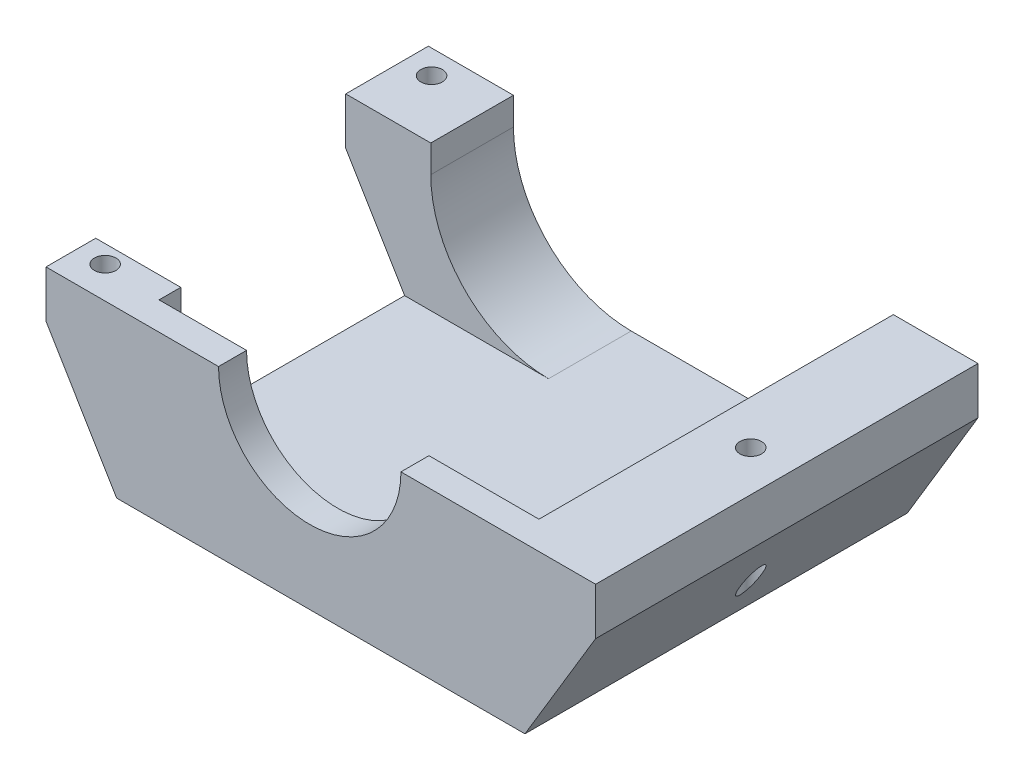
from build123d import *

# Parameters (mm, degrees)
SKETCH1_W                           = 139.991389113
SKETCH1_H                           = 97.393342316
PICOVER_DEPTH                       = 40
PICOVER_DEPTH_BACK                  = 2
SKETCH2_W                           = 96.759944342
SKETCH2_H                           = 90.25941534
OPENINGFORPI_DEPTH                  = 37
SKETCH3_R                           = 23.23056694
HOLETOACCESSSDCARD_DEPTH            = 7.133927
SKETCH4_W                           = 18
SKETCH4_H                           = 97.393342316
CUTAWAYSTHATDEFINESCREWPLATES_DEPTH = 30
BOSS_EXTRUDE1_DEPTH                 = 97.393342
SKETCH6_W                           = 63.672875613
SKETCH6_H                           = 37
HOLEFORPOWERHDMIAUDIO_DEPTH         = 30
SKETCH5_R                           = 2.75
CUT_EXTRUDE5_DEPTH                  = 43
SKETCH7_R                           = 2.75
CUT_EXTRUDE7_DEPTH                  = 30
FILLET1_R                           = 30
FILLET2_R                           = 30


with BuildPart() as part:
    # Sketch1 → PiCover (new body, two sides)
    with BuildSketch(Plane(origin=(0, 0, 0), x_dir=(1, 0, 0), z_dir=(0, 1, 0))) as picover_sk:
        with Locations((69.995694556, 48.696671158)):
            Rectangle(SKETCH1_W, SKETCH1_H)
    extrude(amount=PICOVER_DEPTH)
    extrude(picover_sk.sketch, amount=-PICOVER_DEPTH_BACK)

    # Sketch2 → OpeningForPi (cut)
    with BuildSketch(Plane(origin=(0, 40, 0), x_dir=(1, 0, 0), z_dir=(0, 1, 0))):
        with Locations((70.044375284, 52.263634646)):
            Rectangle(SKETCH2_W, SKETCH2_H)
    extrude(amount=-OPENINGFORPI_DEPTH, mode=Mode.SUBTRACT)

    # Sketch3 → HoleToAccessSDCard (cut)
    with BuildSketch(Plane.XY):
        with Locations((67.175241294, 40)):
            Circle(SKETCH3_R)
    extrude(amount=-HOLETOACCESSSDCARD_DEPTH, mode=Mode.SUBTRACT)

    # Sketch4 → CutAwaysThatDefineScrewPlates (cut)
    with BuildSketch(Plane.XZ.offset(2)):
        with Locations((130.991389113, -48.696671158)):
            Rectangle(SKETCH4_W, SKETCH4_H)
        with Locations((9, -48.696671158)):
            Rectangle(SKETCH4_W, SKETCH4_H)
    extrude(amount=-CUTAWAYSTHATDEFINESCREWPLATES_DEPTH, mode=Mode.SUBTRACT)

    # Sketch11 → Boss-Extrude1 (add)
    with BuildSketch(Plane.XY):
        Polygon((0, 28), (18, 28), (18, -2), align=None)
        Polygon((139.991389113, 28), (121.991389113, 28), (121.991389113, -2), align=None)
    extrude(amount=-BOSS_EXTRUDE1_DEPTH)

    # Sketch6 → HoleForPowerHDMIAudio (cut)
    with BuildSketch(Plane(origin=(21.664403113, 0, 0), x_dir=(0, 0, -1), z_dir=(1, 0, 0))):
        with Locations((44.503037234, 21.5)):
            Rectangle(SKETCH6_W, SKETCH6_H)
    extrude(amount=-HOLEFORPOWERHDMIAUDIO_DEPTH, mode=Mode.SUBTRACT)

    # Sketch5 → Cut-Extrude5 (cut, through all)
    with BuildSketch(Plane(origin=(0, 40, 0), x_dir=(1, 0, 0), z_dir=(0, 1, 0))):
        with Locations((129.624485255, 49.878598174)):
            Circle(SKETCH5_R)
    extrude(amount=-CUT_EXTRUDE5_DEPTH, mode=Mode.SUBTRACT)

    # Sketch7 → Cut-Extrude7 (cut)
    with BuildSketch(Plane(origin=(0, 40, 0), x_dir=(1, 0, 0), z_dir=(0, 1, 0))):
        with Locations((6.934452889, 8.128892452)):
            Circle(SKETCH7_R)
        with Locations((6.934452889, 91.275593332)):
            Circle(SKETCH7_R)
    extrude(amount=-CUT_EXTRUDE7_DEPTH, mode=Mode.SUBTRACT)

    # Fillet1
    fillet1_edges = [part.edges().sort_by_distance(p)[0] for p in [
        (21.664403113, 3, -86.866408678),
    ]]
    fillet(fillet1_edges, radius=FILLET1_R)

    # Fillet2
    fillet2_edges = [part.edges().sort_by_distance(p)[0] for p in [
        (118.424347455, 3, -52.263634646),
    ]]
    fillet(fillet2_edges, radius=FILLET2_R)


solid = part.part
